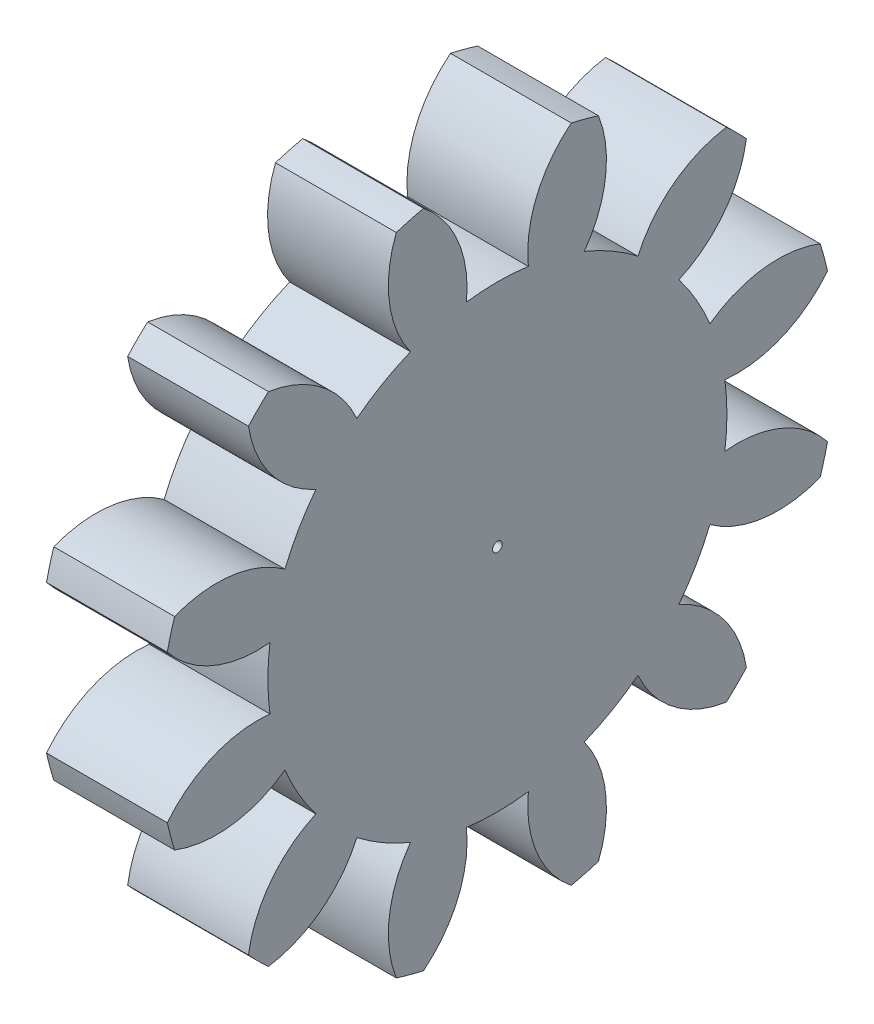
from build123d import *

# Parameters (mm, degrees)
BASPROSKE_W     = 10
BASPROSKE_H     = 28
TOOTHCUT_DEPTH  = 41.841155713
TEETHCUTS_COUNT = 12
TEETHCUTS_ANGLE = 330
BORSKE_R        = 0.4
BORE_DEPTH      = 50.0000508


with BuildPart() as part:
    # BasProSke → Base-Revolve (revolve)
    with BuildSketch(Plane(origin=(0, 0, 0), x_dir=(1, 0, 0), z_dir=(0, 1, 0)), mode=Mode.PRIVATE) as base_revolve_sk:
        with Locations((5, 14)):
            Rectangle(BASPROSKE_W, BASPROSKE_H)
    revolve(base_revolve_sk.sketch.rotate(Axis((-10, 0, 0), (1, 0, 0)), 180), axis=Axis((-10, 0, 0), (1, 0, 0)))

    # TooCutSke → ToothCut (cut, through all)
    with BuildSketch(Plane(origin=(0, 0, 0), x_dir=(0, 0, -1), z_dir=(1, 0, 0))):
        with BuildLine():
            ThreePointArc((2.563820125, 18.825217857), (0, 18.999), (-2.563820125, 18.825217857))
            ThreePointArc((-2.563820125, 18.825217857), (-3.258590946, 23.543348938), (-6.138015408, 27.344977821))
            ThreePointArc((-6.138015408, 27.344977821), (0, 28.0254), (6.138015408, 27.344977821))
            ThreePointArc((6.138015408, 27.344977821), (3.258590946, 23.543348938), (2.563820125, 18.825217857))
        make_face()
    toothcut = extrude(amount=TOOTHCUT_DEPTH, mode=Mode.SUBTRACT)

    # TeethCuts: ToothCut ×12 about axis
    teethcuts_axis = Axis((-10, 0, 0), (1, 0, 0))
    for i in range(1, TEETHCUTS_COUNT):
        add(toothcut.rotate(teethcuts_axis, i * TEETHCUTS_ANGLE / (TEETHCUTS_COUNT - 1)), mode=Mode.SUBTRACT)

    # BorSke → Bore (cut, symmetric)
    with BuildSketch(Plane(origin=(0, 0, 0), x_dir=(0, 0, -1), z_dir=(1, 0, 0))):
        with Locations(Location((0, 0, 0), (0, 0, 180))):
            Circle(BORSKE_R)
    extrude(amount=BORE_DEPTH, both=True, mode=Mode.SUBTRACT)


solid = part.part
